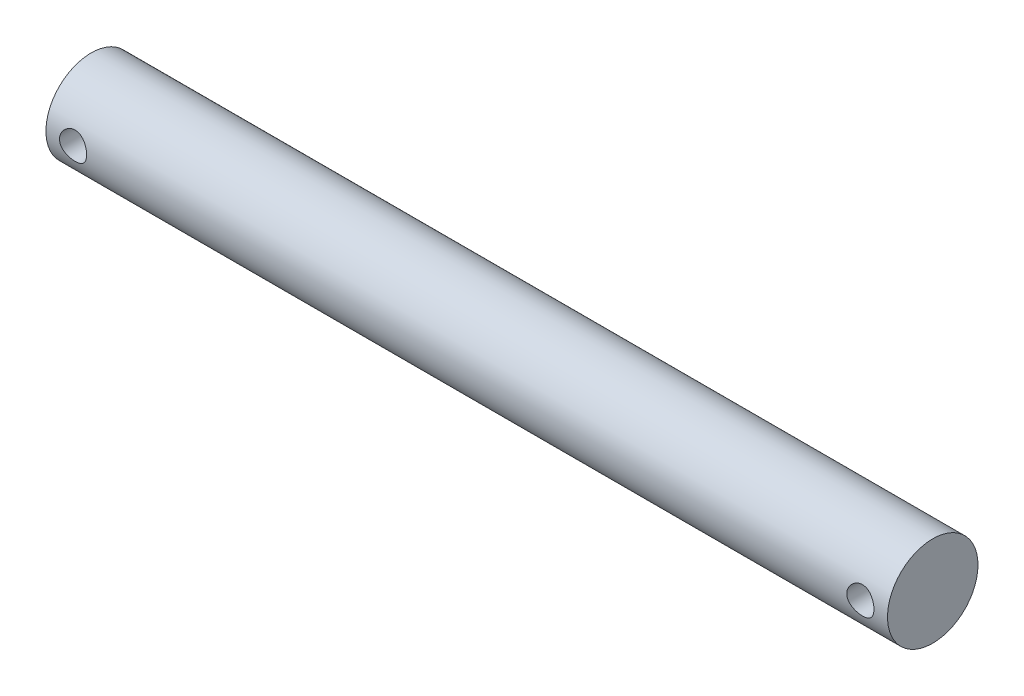
from build123d import *

# Parameters (mm, degrees)
CROQUIS1_R                        = 5
SALIENTE_EXTRUIR1_DEPTH           = 93
CORTAR_EXTRUIR1_REACH             = 7
CROQUIS2_R                        = 1.5
CORTAR_EXTRUIR1_DIRECTION_2_REACH = 7


with BuildPart() as part:
    # Croquis1 → Saliente-Extruir1 (new body)
    with BuildSketch(Plane(origin=(0, 0, 0), x_dir=(0, 0, -1), z_dir=(1, 0, 0))):
        Circle(CROQUIS1_R)
    extrude(amount=SALIENTE_EXTRUIR1_DEPTH)

    # Croquis2 → Cortar-Extruir1 (cut, up to next)
    with BuildSketch(Plane.XY, mode=Mode.PRIVATE) as cortar_extruir1_sk1:
        with Locations((3, 0)):
            Circle(CROQUIS2_R)
    cortar_extruir1_tool1 = extrude(cortar_extruir1_sk1.sketch, amount=-CORTAR_EXTRUIR1_REACH, mode=Mode.PRIVATE) & part.part
    add(cortar_extruir1_tool1.solids().sort_by_distance((3, 0, 0))[0], mode=Mode.SUBTRACT)
    # Croquis2 → Cortar-Extruir1 (cut, up to next)
    with BuildSketch(Plane.XY, mode=Mode.PRIVATE) as cortar_extruir1_sk2:
        with Locations((90, 0)):
            Circle(CROQUIS2_R)
    cortar_extruir1_tool2 = extrude(cortar_extruir1_sk2.sketch, amount=-CORTAR_EXTRUIR1_REACH, mode=Mode.PRIVATE) & part.part
    add(cortar_extruir1_tool2.solids().sort_by_distance((90, 0, 0))[0], mode=Mode.SUBTRACT)

    # Croquis2 → Cortar-Extruir1 direction 2 (cut, up to next)
    with BuildSketch(Plane.XY, mode=Mode.PRIVATE) as cortar_extruir1_direction_2_sk1:
        with Locations((3, 0)):
            Circle(CROQUIS2_R)
    cortar_extruir1_direction_2_tool1 = extrude(cortar_extruir1_direction_2_sk1.sketch, amount=CORTAR_EXTRUIR1_DIRECTION_2_REACH, mode=Mode.PRIVATE) & part.part
    add(cortar_extruir1_direction_2_tool1.solids().sort_by_distance((3, 0, 0))[0], mode=Mode.SUBTRACT)
    # Croquis2 → Cortar-Extruir1 direction 2 (cut, up to next)
    with BuildSketch(Plane.XY, mode=Mode.PRIVATE) as cortar_extruir1_direction_2_sk2:
        with Locations((90, 0)):
            Circle(CROQUIS2_R)
    cortar_extruir1_direction_2_tool2 = extrude(cortar_extruir1_direction_2_sk2.sketch, amount=CORTAR_EXTRUIR1_DIRECTION_2_REACH, mode=Mode.PRIVATE) & part.part
    add(cortar_extruir1_direction_2_tool2.solids().sort_by_distance((90, 0, 0))[0], mode=Mode.SUBTRACT)


solid = part.part
